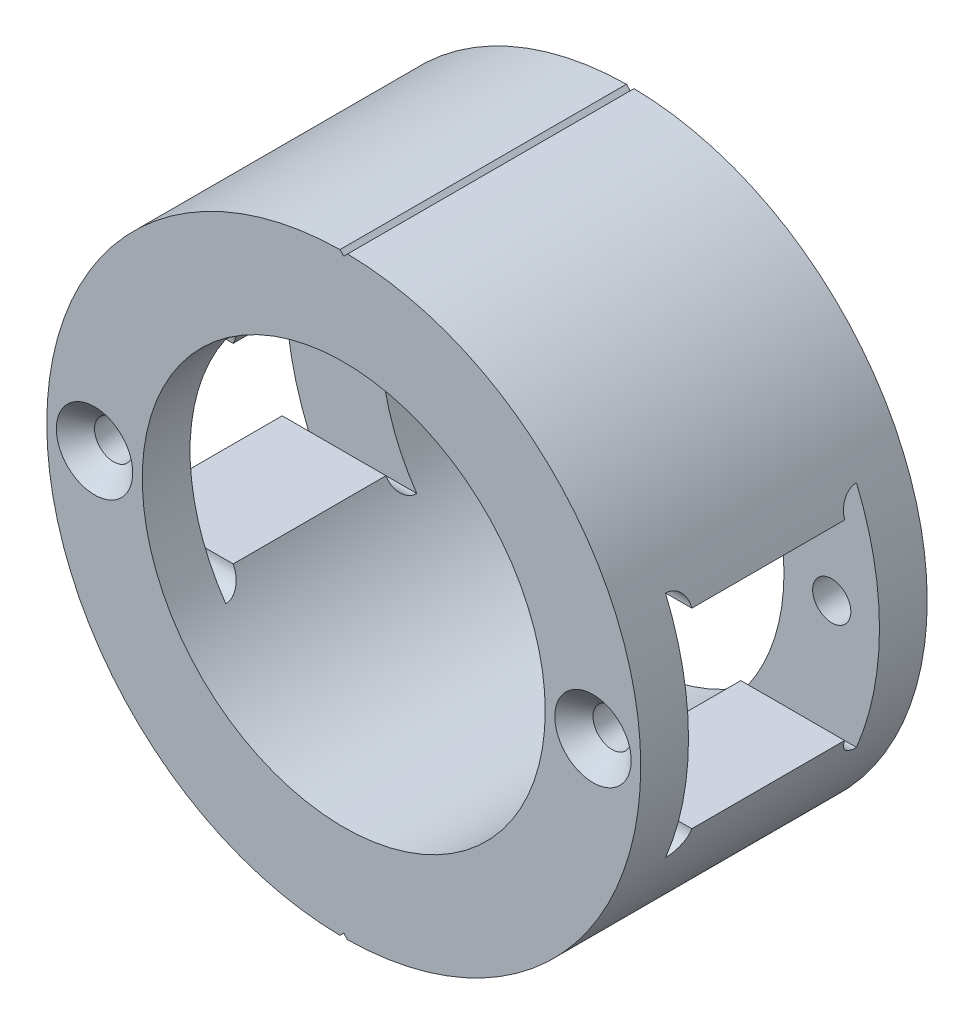
from build123d import *

# Parameters (mm, degrees)
SKIZZE1_R                            = 31.1
SKIZZE1_R_2                          = 21.1
SKIZZE1_R_3                          = 2
AUFSATZ_LINEAR_AUSTRAGEN1_DEPTH      = 15
SKIZZE2_W                            = 20
SKIZZE2_H                            = 20
SCHNITT_LINEAR_AUSTRAGEN1_DEPTH      = 32.1
SCHNITT_LINEAR_AUSTRAGEN1_DEPTH_BACK = 32.1
SKIZZE3_R                            = 2
SCHNITT_LINEAR_AUSTRAGEN2_DEPTH      = 32.1
SCHNITT_LINEAR_AUSTRAGEN2_DEPTH_BACK = 32.1
AUFSATZ_LINEAR_START                 = -12
SKIZZE4_R                            = 21.1
SKIZZE4_R_2                          = 2.5
AUFSATZ_LINEAR_AUSTRAGEN3_DEPTH      = 2
AUFSATZ_LINEAR_START_2               = 10
SKIZZE4_2_R                          = 21.1
SKIZZE4_2_R_2                        = 2.5
AUFSATZ_LINEAR_AUSTRAGEN4_DEPTH      = 5
FASE1_SIZE                           = 2
SCHNITT_LINEAR_START                 = -16
SCHNITT_LINEAR_AUSTRAGEN3_DEPTH      = 32.0000001


with BuildPart() as part:
    # Skizze1 → Aufsatz-Linear austragen1 (new body, symmetric)
    with BuildSketch(Plane.XY):
        Circle(SKIZZE1_R)
        Circle(SKIZZE1_R_2, mode=Mode.SUBTRACT)
        with Locations((-26.1, 0)):
            Circle(SKIZZE1_R_3, mode=Mode.SUBTRACT)
        with Locations((26.1, 0)):
            Circle(SKIZZE1_R_3, mode=Mode.SUBTRACT)
    extrude(amount=AUFSATZ_LINEAR_AUSTRAGEN1_DEPTH, both=True)

    # Skizze2 → Schnitt-Linear austragen1 (cut, two sides)
    with BuildSketch(Plane(origin=(0, 0, 0), x_dir=(0, 0, -1), z_dir=(1, 0, 0))) as schnitt_linear_austragen1_sk:
        Rectangle(SKIZZE2_W, SKIZZE2_H)
    extrude(amount=SCHNITT_LINEAR_AUSTRAGEN1_DEPTH, mode=Mode.SUBTRACT)
    extrude(schnitt_linear_austragen1_sk.sketch, amount=-SCHNITT_LINEAR_AUSTRAGEN1_DEPTH_BACK, mode=Mode.SUBTRACT)

    # Skizze3 → Schnitt-Linear austragen2 (cut, two sides)
    with BuildSketch(Plane(origin=(0, 0, 0), x_dir=(0, 0, -1), z_dir=(1, 0, 0))) as schnitt_linear_austragen2_sk:
        with Locations((10, 10)):
            Circle(SKIZZE3_R)
        with Locations((-10, 10)):
            Circle(SKIZZE3_R)
        with Locations((-10, -10)):
            Circle(SKIZZE3_R)
        with Locations((10, -10)):
            Circle(SKIZZE3_R)
    extrude(amount=SCHNITT_LINEAR_AUSTRAGEN2_DEPTH, mode=Mode.SUBTRACT)
    extrude(schnitt_linear_austragen2_sk.sketch, amount=-SCHNITT_LINEAR_AUSTRAGEN2_DEPTH_BACK, mode=Mode.SUBTRACT)

    # Skizze4 → Aufsatz-Linear austragen3 (add)
    with BuildSketch(Plane.XY.offset(AUFSATZ_LINEAR_START)):
        with BuildLine():
            ThreePointArc((-14.515439923, 27.504763293), (6.247459032, 30.466034459), (24.169142857, 19.571983383))
            ThreePointArc((24.169142857, 19.571983383), (31.1, 0), (24.169142857, -19.571983383))
            ThreePointArc((24.169142857, -19.571983383), (6.247459032, -30.466034459), (-14.515439923, -27.504763293))
            ThreePointArc((-14.515439923, -27.504763293), (-31.1, 0), (-14.515439923, 27.504763293))
        make_face()
        Circle(SKIZZE4_R, mode=Mode.SUBTRACT)
        with Locations((-26.1, 0)):
            Circle(SKIZZE4_R_2, mode=Mode.SUBTRACT)
        with Locations((26.1, 0)):
            Circle(SKIZZE4_R_2, mode=Mode.SUBTRACT)
    extrude(amount=AUFSATZ_LINEAR_AUSTRAGEN3_DEPTH)

    # Skizze4_2 → Aufsatz-Linear austragen4 (add)
    with BuildSketch(Plane.XY.offset(AUFSATZ_LINEAR_START_2)):
        with BuildLine():
            ThreePointArc((-14.515439923, 27.504763293), (6.247459032, 30.466034459), (24.169142857, 19.571983383))
            ThreePointArc((24.169142857, 19.571983383), (31.1, 0), (24.169142857, -19.571983383))
            ThreePointArc((24.169142857, -19.571983383), (6.247459032, -30.466034459), (-14.515439923, -27.504763293))
            ThreePointArc((-14.515439923, -27.504763293), (-31.1, 0), (-14.515439923, 27.504763293))
        make_face()
        Circle(SKIZZE4_2_R, mode=Mode.SUBTRACT)
        with Locations((-26.1, 0)):
            Circle(SKIZZE4_2_R_2, mode=Mode.SUBTRACT)
        with Locations((26.1, 0)):
            Circle(SKIZZE4_2_R_2, mode=Mode.SUBTRACT)
    extrude(amount=AUFSATZ_LINEAR_AUSTRAGEN4_DEPTH)

    # Fase1
    fase1_edges = [part.edges().sort_by_distance(p)[0] for p in [
        (24.1, 0, -15),
        (24.1, 0, 15),
        (-28.1, 0, -15),
        (-28.1, 0, 15),
    ]]
    chamfer(fase1_edges, length=FASE1_SIZE)

    # Skizze5 → Schnitt-Linear austragen3 (cut)
    with BuildSketch(Plane.XY.offset(SCHNITT_LINEAR_START)):
        Polygon((-0.4, 31.1), (0, 30.7), (0.4, 31.1), align=None)
    schnitt_linear_austragen3 = extrude(amount=SCHNITT_LINEAR_AUSTRAGEN3_DEPTH, mode=Mode.SUBTRACT)

    # Spiegeln1: Schnitt-Linear austragen3 across plane
    add(schnitt_linear_austragen3.mirror(Plane.ZX), mode=Mode.SUBTRACT)


solid = part.part
